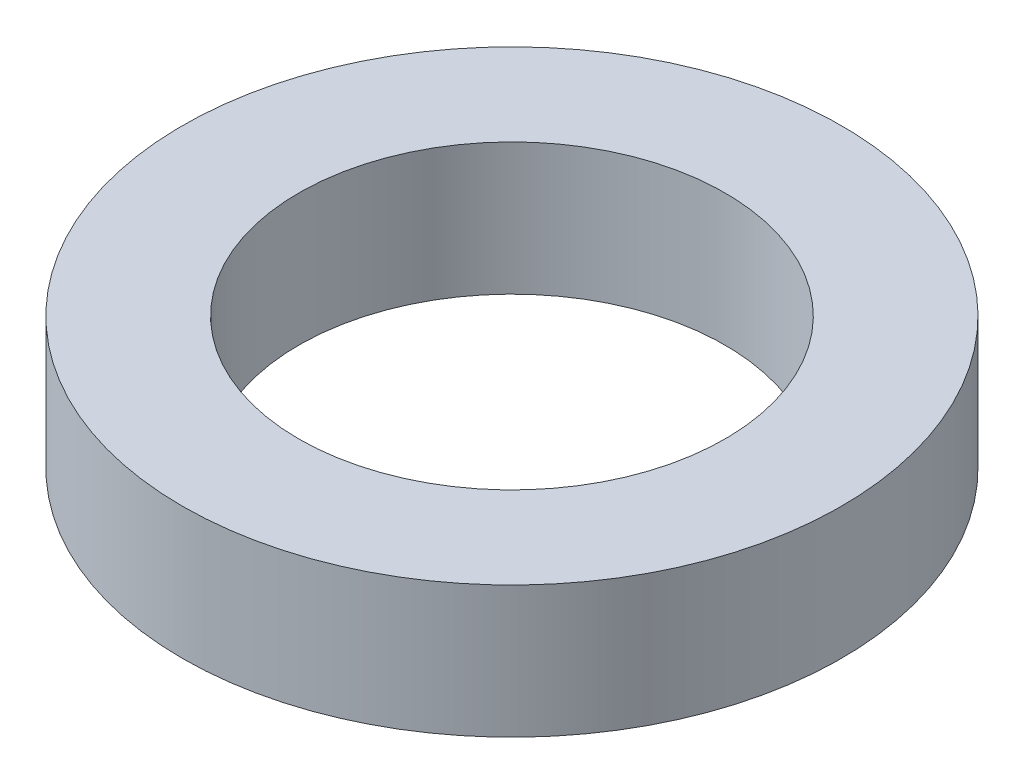
from build123d import *

# Parameters (mm, degrees)
SKETCH1_R           = 9.525
SKETCH1_R_2         = 6.1595
BOSS_EXTRUDE1_DEPTH = 3.81


with BuildPart() as part:
    # Sketch1 → Boss-Extrude1 (new body)
    with BuildSketch(Plane(origin=(0, 0, 0), x_dir=(1, 0, 0), z_dir=(0, 1, 0))):
        Circle(SKETCH1_R)
        Circle(SKETCH1_R_2, mode=Mode.SUBTRACT)
    extrude(amount=BOSS_EXTRUDE1_DEPTH)


solid = part.part
